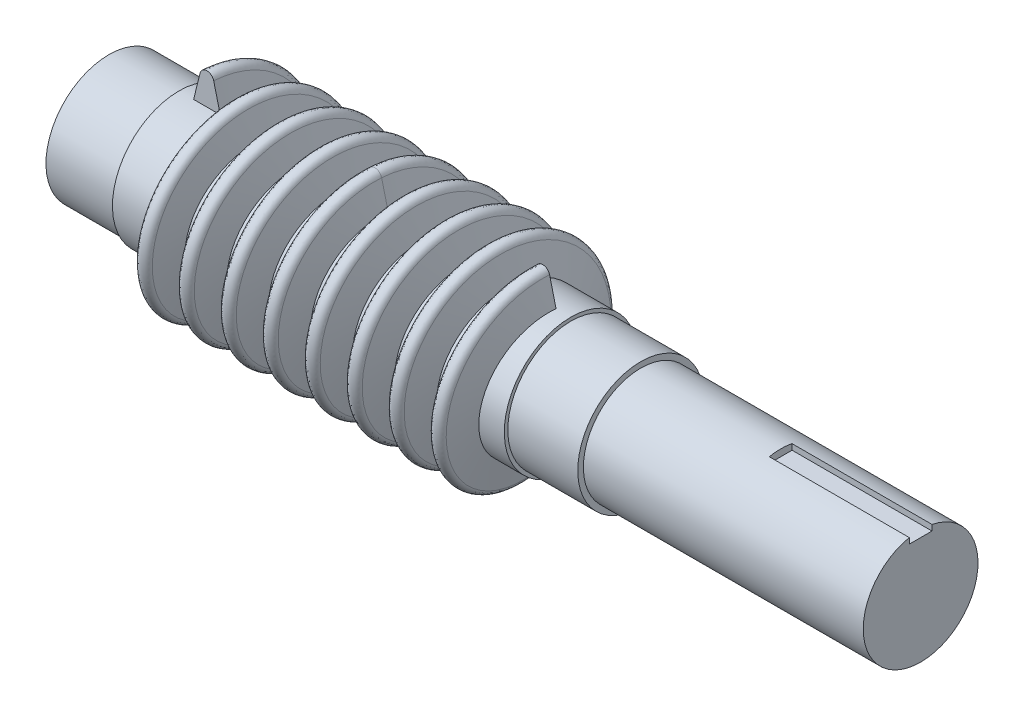
from build123d import *

# Parameters (mm, degrees)
SWEEP1_PITCH       = 6
SWEEP1_HEIGHT      = 24
SWEEP1_RADIUS      = 9.5
SWEEP1_START_ANGLE = -90
SWEEP2_PITCH       = 6
SWEEP2_HEIGHT      = 24
SWEEP2_RADIUS      = 9.5
SWEEP2_START_ANGLE = -90
SKETCH7_W          = 3.25
SKETCH7_H          = 1.5
CUT_EXTRUDE1_DEPTH = 20
SCALE1_SCALE       = 0.5


with BuildPart() as part:
    # Sketch1 → Revolve1 (revolve)
    with BuildSketch(Plane.XY):
        Polygon((78, -11.75), (-38, -11.75), (-38, -2.75), (-28, -2.75), (-28, -2.25), (28, -2.25), (28, -2.75), (38, -2.75), (38, -3.55), (78, -3.55), align=None)
    revolve(axis=Axis((78, -11.75, 0), (-1, 0, 0)))

    # Sweep1: sweep along a helix
    with BuildLine() as sweep1_path:
        add(Helix(SWEEP1_PITCH, SWEEP1_HEIGHT, SWEEP1_RADIUS, center=(0, -11.75, 0), direction=(1, 0, 0), lefthand=True, mode=Mode.PRIVATE).rotate(Axis((0, -11.75, 0), (1, 0, 0)), SWEEP1_START_ANGLE))
    # Sketch3 → Sweep1 (sweep)
    with BuildSketch(Plane.XY):
        with BuildLine():
            Line((-0.97049399, 1.491125309), (-1.9, -2.25))
            Line((-1.9, -2.25), (-1.9, -2.95))
            Line((-1.9, -2.95), (1.9, -2.95))
            Line((1.9, -2.95), (1.9, -2.25))
            Line((1.9, -2.25), (0.97049399, 1.491125309))
            ThreePointArc((0.97049399, 1.491125309), (0, 2.25), (-0.97049399, 1.491125309))
        make_face()
    sweep(path=sweep1_path.line, is_frenet=True)

    # Sweep2: sweep along a helix
    with BuildLine() as sweep2_path:
        add(Helix(SWEEP2_PITCH, SWEEP2_HEIGHT, SWEEP2_RADIUS, center=(0, -11.75, 0), direction=(-1, 0, 0), lefthand=True, mode=Mode.PRIVATE).rotate(Axis((0, -11.75, 0), (-1, 0, 0)), SWEEP2_START_ANGLE))
    # Sketch6 → Sweep2 (sweep)
    with BuildSketch(Plane.XY):
        with BuildLine():
            Line((-0.97049399, 1.491125309), (-1.9, -2.25))
            Line((-1.9, -2.25), (-1.9, -2.95))
            Line((-1.9, -2.95), (1.9, -2.95))
            Line((1.9, -2.95), (1.9, -2.25))
            Line((1.9, -2.25), (0.97049399, 1.491125309))
            ThreePointArc((0.97049399, 1.491125309), (0, 2.25), (-0.97049399, 1.491125309))
        make_face()
    sweep(path=sweep2_path.line, is_frenet=True)

    # Sketch7 → Cut-Extrude1 (cut)
    with BuildSketch(Plane(origin=(78, 0, 0), x_dir=(0, 0, -1), z_dir=(1, 0, 0))):
        with Locations((0, -3.78)):
            Rectangle(SKETCH7_W, SKETCH7_H)
    extrude(amount=-CUT_EXTRUDE1_DEPTH, mode=Mode.SUBTRACT)


with BuildPart() as part_1:
    # Scale1: scaled about (13.450934932, -11.762800288, 2.5e-08)
    add(part.part.scale(SCALE1_SCALE).moved(Location((6.725467466, -5.881400144, 1.2e-08))))


solid = part_1.part
